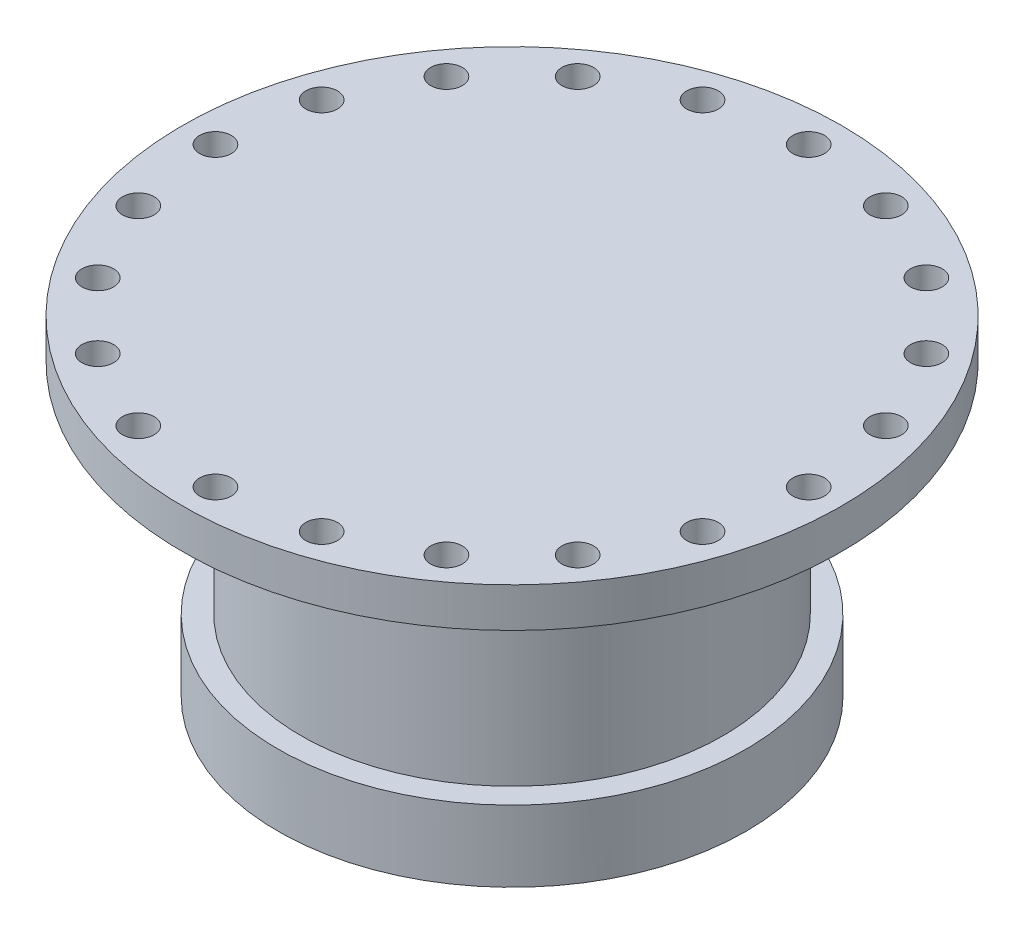
from build123d import *

# Parameters (mm, degrees)
ESBO_O2_R             = 12
CORTE_EXTRUS_O1_DEPTH = 250.990148264


with BuildPart() as part:
    # Esboço1 → Revolução1 (revolve)
    with BuildSketch(Plane.XY):
        with BuildLine():
            Line((0, 4196), (250, 4196))
            Line((250, 4196), (250, 4166))
            Line((250, 4166), (180, 4166))
            Line((180, 4166), (174, 4160))
            Line((174, 4160), (160, 4160))
            Line((160, 4160), (160, 4000))
            Line((160, 4000), (177.5, 4000))
            Line((177.5, 4000), (177.5, 3946.009851736))
            ThreePointArc((177.5, 3946.009851736), (88.77242151, 3949.002336943), (0, 3950))
            Line((0, 3950), (0, 4000))
            Line((0, 4000), (140, 4000))
            Line((140, 4000), (140, 4160))
            Line((140, 4160), (0, 4160))
            Line((0, 4160), (0, 4196))
        make_face()
    revolve(axis=Axis((0, 113.656700564, 0), (0, 1, 0)))

    # Esboço2 → Corte-extrusão1 (cut, through all)
    with BuildSketch(Plane(origin=(0, 4196, 0), x_dir=(1, 0, 0), z_dir=(0, 1, 0))):
        with Locations((0, 225)):
            Circle(ESBO_O2_R)
        with Locations((69.528823734, 213.987716166)):
            Circle(ESBO_O2_R)
        with Locations((132.251681766, 182.028823734)):
            Circle(ESBO_O2_R)
        with Locations((182.028823734, 132.251681766)):
            Circle(ESBO_O2_R)
        with Locations((213.987716166, 69.528823734)):
            Circle(ESBO_O2_R)
        with Locations((225, 0)):
            Circle(ESBO_O2_R)
        with Locations((213.987716166, -69.528823734)):
            Circle(ESBO_O2_R)
        with Locations((182.028823734, -132.251681766)):
            Circle(ESBO_O2_R)
        with Locations((132.251681766, -182.028823734)):
            Circle(ESBO_O2_R)
        with Locations((69.528823734, -213.987716166)):
            Circle(ESBO_O2_R)
        with Locations((0, -225)):
            Circle(ESBO_O2_R)
        with Locations((-69.528823734, -213.987716166)):
            Circle(ESBO_O2_R)
        with Locations((-132.251681766, -182.028823734)):
            Circle(ESBO_O2_R)
        with Locations((-182.028823734, -132.251681766)):
            Circle(ESBO_O2_R)
        with Locations((-213.987716166, -69.528823734)):
            Circle(ESBO_O2_R)
        with Locations((-225, 0)):
            Circle(ESBO_O2_R)
        with Locations((-213.987716166, 69.528823734)):
            Circle(ESBO_O2_R)
        with Locations((-182.028823734, 132.251681766)):
            Circle(ESBO_O2_R)
        with Locations((-132.251681766, 182.028823734)):
            Circle(ESBO_O2_R)
        with Locations((-69.528823734, 213.987716166)):
            Circle(ESBO_O2_R)
    extrude(amount=-CORTE_EXTRUS_O1_DEPTH, mode=Mode.SUBTRACT)


solid = part.part
